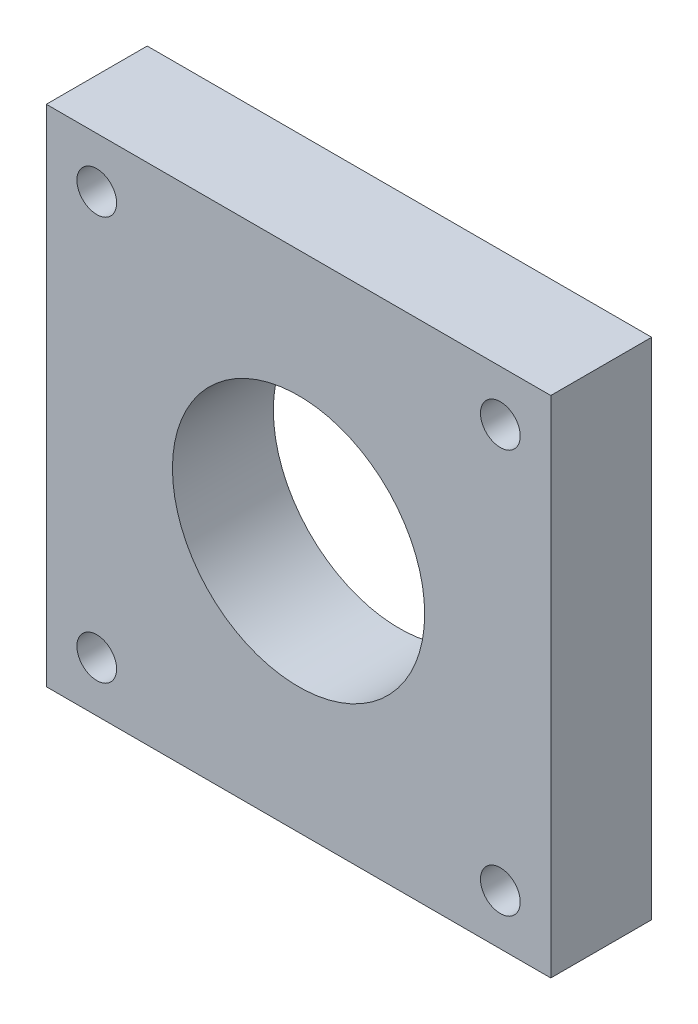
from build123d import *

# Parameters (mm, degrees)
SKETCH1_W           = 50.8
SKETCH1_H           = 50.8
SKETCH1_R           = 2
SKETCH1_R_2         = 12.7
BOSS_EXTRUDE1_DEPTH = 10.16


with BuildPart() as part:
    # Sketch1 → Boss-Extrude1 (new body)
    with BuildSketch(Plane.XY):
        Rectangle(SKETCH1_W, SKETCH1_H)
        with Locations((-20.32, 20.32)):
            Circle(SKETCH1_R, mode=Mode.SUBTRACT)
        with Locations((20.32, 20.32)):
            Circle(SKETCH1_R, mode=Mode.SUBTRACT)
        with Locations((20.32, -20.32)):
            Circle(SKETCH1_R, mode=Mode.SUBTRACT)
        with Locations((-20.32, -20.32)):
            Circle(SKETCH1_R, mode=Mode.SUBTRACT)
        Circle(SKETCH1_R_2, mode=Mode.SUBTRACT)
    extrude(amount=BOSS_EXTRUDE1_DEPTH)


solid = part.part
